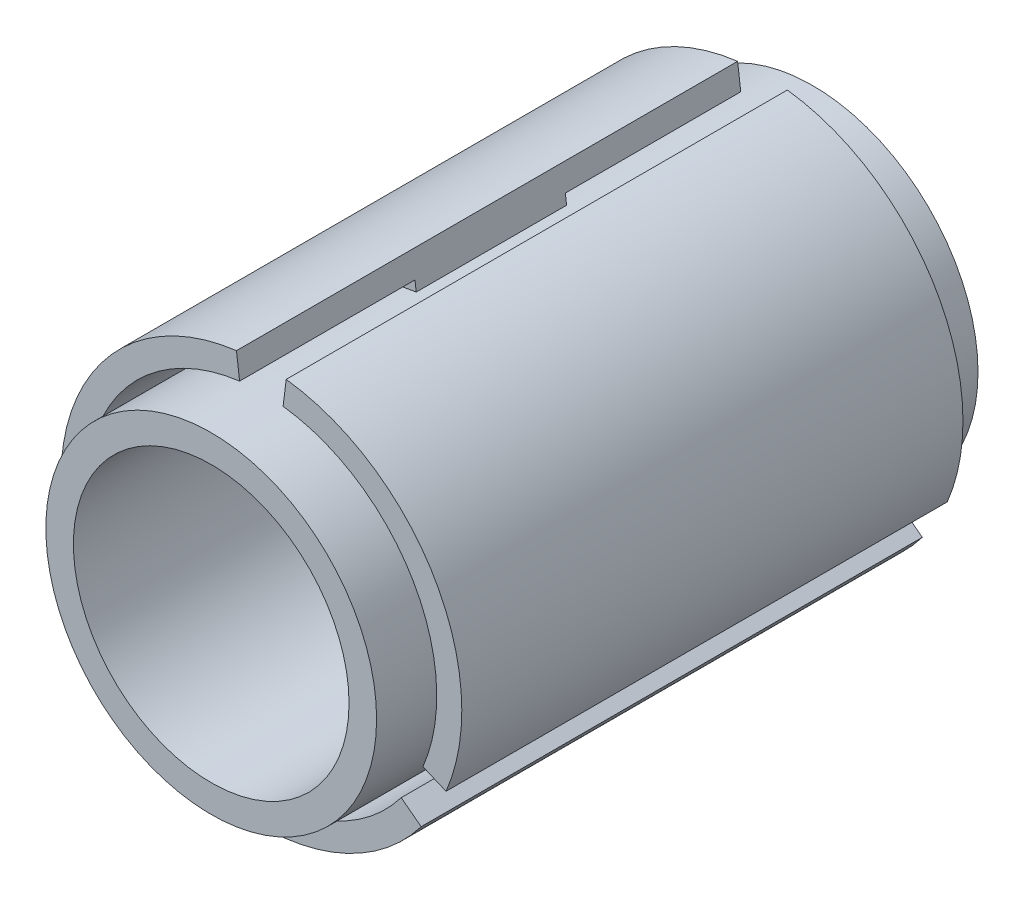
from build123d import *

# Parameters (mm, degrees)
CROQUIS1_R                 = 33
SALIENTE_EXTRUIR1_DEPTH    = 15
SALIENTE_EXTRUIR2_DEPTH    = 15
SALIENTE_EXTRUIR3_DEPTH    = 50
CROQUIS4_R                 = 33
SALIENTE_EXTRUIR4_DEPTH    = 60
CROQUIS5_R                 = 27.5
CORTAR_EXTRUIR1_DEPTH      = 40
CROQUIS6_R                 = 27.5
CORTAR_EXTRUIR2_DEPTH      = 75
CROQUIS7_R                 = 1
CORTAR_EXTRUIR3_DEPTH      = 61
CORTAR_EXTRUIR3_DEPTH_BACK = 61


with BuildPart() as part:
    # Croquis1 → Saliente-Extruir1 (new body, symmetric)
    with BuildSketch(Plane.XY):
        Circle(CROQUIS1_R)
    extrude(amount=SALIENTE_EXTRUIR1_DEPTH, both=True)

    # Croquis2 → Saliente-Extruir2 (add, symmetric)
    with BuildSketch(Plane.XY):
        with BuildLine():
            Line((-4.961389384, 39.691115069), (-4.093146241, 32.745169932))
            ThreePointArc((-4.093146241, 32.745169932), (-28.578838325, 16.5), (-30.404722133, -12.827816339))
            Line((-30.404722133, -12.827816339), (-36.854208646, -15.54886829))
            ThreePointArc((-36.854208646, -15.54886829), (-34.641016151, 20), (-4.961389384, 39.691115069))
        make_face()
        with BuildLine():
            Line((4.961389384, 39.691115069), (4.093146241, 32.745169932))
            ThreePointArc((4.093146241, 32.745169932), (28.578838325, 16.5), (30.404722133, -12.827816339))
            Line((30.404722133, -12.827816339), (36.854208646, -15.54886829))
            ThreePointArc((36.854208646, -15.54886829), (34.641016151, 20), (4.961389384, 39.691115069))
        make_face()
        with BuildLine():
            Line((31.892819262, -24.142246779), (26.311575891, -19.917353592))
            ThreePointArc((26.311575891, -19.917353592), (0, -33), (-26.311575891, -19.917353592))
            Line((-26.311575891, -19.917353592), (-31.892819262, -24.142246779))
            ThreePointArc((-31.892819262, -24.142246779), (0, -40), (31.892819262, -24.142246779))
        make_face()
    extrude(amount=SALIENTE_EXTRUIR2_DEPTH, both=True)

    # Croquis3 → Saliente-Extruir3 (add, symmetric)
    with BuildSketch(Plane.XY):
        with BuildLine():
            Line((-4.341215711, 34.729725685), (-4.961389384, 39.691115069))
            ThreePointArc((-4.961389384, 39.691115069), (-34.641016151, 20), (-36.854208646, -15.54886829))
            Line((-36.854208646, -15.54886829), (-32.247432565, -13.605259754))
            ThreePointArc((-32.247432565, -13.605259754), (-30.310889132, 17.5), (-4.341215711, 34.729725685))
        make_face()
        with BuildLine():
            Line((4.341215711, 34.729725685), (4.961389384, 39.691115069))
            ThreePointArc((4.961389384, 39.691115069), (34.641016151, 20), (36.854208646, -15.54886829))
            Line((36.854208646, -15.54886829), (32.247432565, -13.605259754))
            ThreePointArc((32.247432565, -13.605259754), (30.310889132, 17.5), (4.341215711, 34.729725685))
        make_face()
        with BuildLine():
            Line((31.892819262, -24.142246779), (27.906216854, -21.124465931))
            ThreePointArc((27.906216854, -21.124465931), (0, -35), (-27.906216854, -21.124465931))
            Line((-27.906216854, -21.124465931), (-31.892819262, -24.142246779))
            ThreePointArc((-31.892819262, -24.142246779), (0, -40), (31.892819262, -24.142246779))
        make_face()
    extrude(amount=SALIENTE_EXTRUIR3_DEPTH, both=True)

    # Croquis4 → Saliente-Extruir4 (add, symmetric)
    with BuildSketch(Plane.XY):
        Circle(CROQUIS4_R)
    extrude(amount=SALIENTE_EXTRUIR4_DEPTH, both=True)

    # Croquis5 → Cortar-Extruir1 (cut)
    with BuildSketch(Plane.XY.offset(60)):
        Circle(CROQUIS5_R)
    extrude(amount=-CORTAR_EXTRUIR1_DEPTH, mode=Mode.SUBTRACT)

    # Croquis6 → Cortar-Extruir2 (cut)
    with BuildSketch(Plane(origin=(0, 0, -60), x_dir=(-1, 0, 0), z_dir=(0, 0, -1))):
        Circle(CROQUIS6_R)
    extrude(amount=-CORTAR_EXTRUIR2_DEPTH, mode=Mode.SUBTRACT)

    # Croquis7 → Cortar-Extruir3 (cut, two sides)
    with BuildSketch(Plane.XY) as cortar_extruir3_sk:
        with Locations((5, 5)):
            Circle(CROQUIS7_R)
        with Locations((-5, 5)):
            Circle(CROQUIS7_R)
        with Locations((-5, -5)):
            Circle(CROQUIS7_R)
        with Locations((5, -5)):
            Circle(CROQUIS7_R)
    extrude(amount=CORTAR_EXTRUIR3_DEPTH, mode=Mode.SUBTRACT)
    extrude(cortar_extruir3_sk.sketch, amount=-CORTAR_EXTRUIR3_DEPTH_BACK, mode=Mode.SUBTRACT)


solid = part.part
